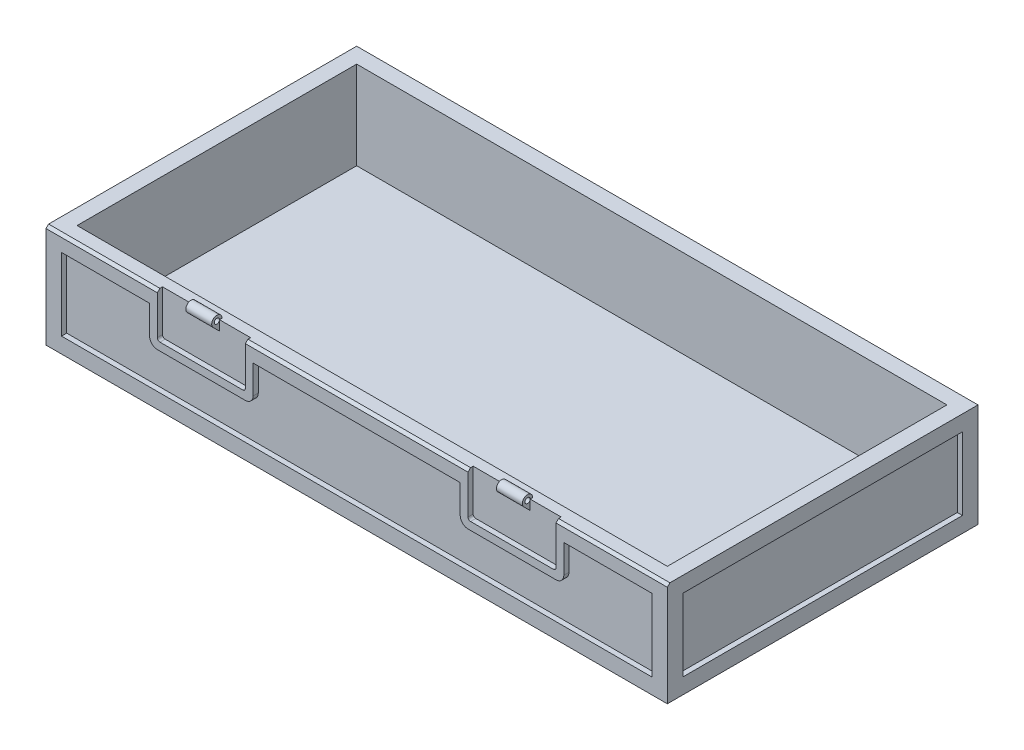
from build123d import *

# Parameters (mm, degrees)
SKETCH1_W                = 120
SKETCH1_H                = 60
BOSS_EXTRUDE1_DEPTH      = 20
SKETCH2_W                = 114
SKETCH2_H                = 54
CUT_EXTRUDE1_DEPTH       = 17
CUT_EXTRUDE2_DEPTH       = 1
CUT_EXTRUDE3_DEPTH       = 1
SKETCH5_W                = 54
SKETCH5_H                = 14
CUT_EXTRUDE4_DEPTH       = 1
SKETCH6_W                = 54
SKETCH6_H                = 14
CUT_EXTRUDE5_DEPTH       = 1
SKETCH7_W                = 114
SKETCH7_H                = 14
CUT_EXTRUDE6_DEPTH       = 1
SKETCH8_W                = 114
SKETCH8_H                = 54
CUT_EXTRUDE7_DEPTH       = 1
BOSS_EXTRUDE2_DEPTH      = 3
BOSS_EXTRUDE2_DEPTH_BACK = 0.5
CUT_EXTRUDE8_DEPTH       = 5
BOSS_EXTRUDE3_DEPTH      = 2
BOSS_EXTRUDE3_DEPTH_BACK = 0.5
CUT_EXTRUDE9_DEPTH       = 5
CUT_EXTRUDE10_DEPTH      = 23
CUT_EXTRUDE11_DEPTH      = 43
CUT_EXTRUDE12_DEPTH      = 43
BOSS_EXTRUDE5_DEPTH      = 1


with BuildPart() as part:
    # Sketch1 → Boss-Extrude1 (new body)
    with BuildSketch(Plane(origin=(0, 0, 0), x_dir=(1, 0, 0), z_dir=(0, 1, 0))):
        with Locations((60, 30)):
            Rectangle(SKETCH1_W, SKETCH1_H)
    extrude(amount=BOSS_EXTRUDE1_DEPTH)

    # Sketch2 → Cut-Extrude1 (cut)
    with BuildSketch(Plane(origin=(0, 20, 0), x_dir=(1, 0, 0), z_dir=(0, 1, 0))):
        with Locations((60, 30)):
            Rectangle(SKETCH2_W, SKETCH2_H)
    extrude(amount=-CUT_EXTRUDE1_DEPTH, mode=Mode.SUBTRACT)

    # Sketch3 → Cut-Extrude2 (cut)
    with BuildSketch(Plane.XY):
        with BuildLine():
            Line((38.5, 20), (21.5, 20))
            Line((21.5, 20), (21.5, 12))
            ThreePointArc((21.5, 12), (21.646446609, 11.646446609), (22, 11.5))
            Line((22, 11.5), (38, 11.5))
            ThreePointArc((38, 11.5), (38.353553391, 11.646446609), (38.5, 12))
            Line((38.5, 12), (38.5, 20))
        make_face()
        with BuildLine():
            Line((98.5, 12), (98.5, 20))
            Line((98.5, 20), (81.5, 20))
            Line((81.5, 20), (81.5, 12))
            ThreePointArc((81.5, 12), (81.646446609, 11.646446609), (82, 11.5))
            Line((82, 11.5), (98, 11.5))
            ThreePointArc((98, 11.5), (98.353553391, 11.646446609), (98.5, 12))
        make_face()
    extrude(amount=-CUT_EXTRUDE2_DEPTH, mode=Mode.SUBTRACT)

    # Sketch4 → Cut-Extrude3 (cut)
    with BuildSketch(Plane.XY):
        with BuildLine():
            Line((20, 17), (3, 17))
            Line((3, 17), (3, 3))
            Line((3, 3), (117, 3))
            Line((117, 3), (117, 17))
            Line((117, 17), (100, 17))
            Line((100, 17), (100, 11.5))
            ThreePointArc((100, 11.5), (99.560660172, 10.439339828), (98.5, 10))
            Line((98.5, 10), (81.5, 10))
            ThreePointArc((81.5, 10), (80.439339828, 10.439339828), (80, 11.5))
            Line((80, 11.5), (80, 17))
            Line((80, 17), (60, 17))
            Line((60, 17), (40, 17))
            Line((40, 17), (40, 11.5))
            ThreePointArc((40, 11.5), (39.560660172, 10.439339828), (38.5, 10))
            Line((38.5, 10), (21.5, 10))
            ThreePointArc((21.5, 10), (20.439339828, 10.439339828), (20, 11.5))
            Line((20, 11.5), (20, 17))
        make_face()
    extrude(amount=-CUT_EXTRUDE3_DEPTH, mode=Mode.SUBTRACT)

    # Sketch5 → Cut-Extrude4 (cut)
    with BuildSketch(Plane.ZY):
        with Locations((-30, 10)):
            Rectangle(SKETCH5_W, SKETCH5_H)
    extrude(amount=-CUT_EXTRUDE4_DEPTH, mode=Mode.SUBTRACT)

    # Sketch6 → Cut-Extrude5 (cut)
    with BuildSketch(Plane(origin=(120, 0, 0), x_dir=(0, 0, -1), z_dir=(1, 0, 0))):
        with Locations((30, 10)):
            Rectangle(SKETCH6_W, SKETCH6_H)
    extrude(amount=-CUT_EXTRUDE5_DEPTH, mode=Mode.SUBTRACT)

    # Sketch7 → Cut-Extrude6 (cut)
    with BuildSketch(Plane(origin=(0, 0, -60), x_dir=(-1, 0, 0), z_dir=(0, 0, -1))):
        with Locations((-60, 10)):
            Rectangle(SKETCH7_W, SKETCH7_H)
    extrude(amount=-CUT_EXTRUDE6_DEPTH, mode=Mode.SUBTRACT)

    # Sketch8 → Cut-Extrude7 (cut)
    with BuildSketch(Plane.XZ):
        with Locations((60, -30)):
            Rectangle(SKETCH8_W, SKETCH8_H)
    extrude(amount=-CUT_EXTRUDE7_DEPTH, mode=Mode.SUBTRACT)

    # Sketch9 → Boss-Extrude2 (add, two sides)
    with BuildSketch(Plane.XY.offset(-1)) as boss_extrude2_sk:
        Polygon((32.5, 20), (30, 20), (27.5, 20), (27.5, 18), (32.5, 18), align=None)
        Polygon((27.5, 20), (30, 20), (32.5, 20), (32.5, 21), (27.5, 21), align=None)
    extrude(amount=BOSS_EXTRUDE2_DEPTH)
    extrude(boss_extrude2_sk.sketch, amount=-BOSS_EXTRUDE2_DEPTH_BACK)

    # Sketch11 → Cut-Extrude8 (cut)
    with BuildSketch(Plane(origin=(32.5, 0, 0), x_dir=(0, 0, -1), z_dir=(1, 0, 0))):
        with BuildLine():
            Line((1, 18.085786438), (-0.207106781, 19.292893219))
            ThreePointArc((-0.207106781, 19.292893219), (-0.423879533, 20.382683432), (0.5, 21))
            Line((0.5, 21), (-2, 21))
            Line((-2, 21), (-2, 18))
            Line((-2, 18), (1, 18))
            Line((1, 18), (1, 18.085786438))
        make_face()
        with BuildLine():
            ThreePointArc((0.5, 21), (1.207106781, 20.707106781), (1.5, 20))
            Line((1.5, 20), (1.5, 21))
            Line((1.5, 21), (0.5, 21))
        make_face()
        with BuildLine():
            ThreePointArc((0.146446609, 19.646446609), (0.691341716, 19.538060234), (1, 20))
            Line((1, 20), (0.5, 20))
            Line((0.5, 20), (0.146446609, 19.646446609))
        make_face()
        with BuildLine():
            Line((0.5, 20), (1, 20))
            ThreePointArc((1, 20), (0.308658284, 20.461939766), (0.146446609, 19.646446609))
            Line((0.146446609, 19.646446609), (0.5, 20))
        make_face()
    extrude(amount=-CUT_EXTRUDE8_DEPTH, mode=Mode.SUBTRACT)

    # Sketch12 → Boss-Extrude3 (add, two sides)
    with BuildSketch(Plane.XY.offset(-1)) as boss_extrude3_sk:
        Polygon((87.5, 21), (87.5, 20), (87.5, 18), (92.5, 18), (92.5, 21), align=None)
    extrude(amount=BOSS_EXTRUDE3_DEPTH)
    extrude(boss_extrude3_sk.sketch, amount=-BOSS_EXTRUDE3_DEPTH_BACK)

    # Sketch13 → Cut-Extrude9 (cut)
    with BuildSketch(Plane(origin=(92.5, 0, 0), x_dir=(0, 0, -1), z_dir=(1, 0, 0))):
        with BuildLine():
            Line((1, 18.085786438), (-0.207106781, 19.292893219))
            ThreePointArc((-0.207106781, 19.292893219), (-0.423879533, 20.382683432), (0.5, 21))
            Line((0.5, 21), (-1, 21))
            Line((-1, 21), (-1, 18))
            Line((-1, 18), (1, 18))
            Line((1, 18), (1, 18.085786438))
        make_face()
        with BuildLine():
            ThreePointArc((0.146446609, 19.646446609), (0.691341716, 19.538060234), (1, 20))
            Line((1, 20), (0.5, 20))
            Line((0.5, 20), (0.146446609, 19.646446609))
        make_face()
        with BuildLine():
            Line((0.5, 20), (1, 20))
            ThreePointArc((1, 20), (0.308658284, 20.461939766), (0.146446609, 19.646446609))
            Line((0.146446609, 19.646446609), (0.5, 20))
        make_face()
        with BuildLine():
            ThreePointArc((0.5, 21), (1.207106781, 20.707106781), (1.5, 20))
            Line((1.5, 20), (1.5, 21))
            Line((1.5, 21), (0.5, 21))
        make_face()
    extrude(amount=-CUT_EXTRUDE9_DEPTH, mode=Mode.SUBTRACT)

    # Sketch14 → Cut-Extrude10 (cut)
    with BuildSketch(Plane.ZY):
        Polygon((0, 19.5), (0, 20), (-0.5, 20), align=None)
    extrude(amount=-CUT_EXTRUDE10_DEPTH, mode=Mode.SUBTRACT)

    # Sketch15 → Cut-Extrude11 (cut)
    with BuildSketch(Plane.ZY.offset(-38.5)):
        Polygon((0, 20), (-0.5, 20), (0, 19.5), align=None)
    extrude(amount=-CUT_EXTRUDE11_DEPTH, mode=Mode.SUBTRACT)

    # Sketch16 → Cut-Extrude12 (cut)
    with BuildSketch(Plane.ZY.offset(-98.5)):
        Polygon((0, 20), (-0.5, 20), (0, 19.5), align=None)
    extrude(amount=-CUT_EXTRUDE12_DEPTH, mode=Mode.SUBTRACT)

    # Sketch18 → Boss-Extrude5 (add)
    with BuildSketch(Plane(origin=(0, 0, 0), x_dir=(-1, 0, 0), z_dir=(0, -1, 0))):
        Polygon((-46.5, 36.75), (-48, 36), (-48, 24), (-60, 24), (-60, 22.5), (-46.5, 22.5), align=None)
        Polygon((-60, 24), (-72, 24), (-73.5, 23.25), (-73.5, 22.5), (-60, 22.5), align=None)
        Polygon((-72, 36), (-48, 36), (-46.5, 36.75), (-46.5, 37.5), (-73.5, 37.5), (-73.5, 23.25), (-72, 24), align=None)
    extrude(amount=-BOSS_EXTRUDE5_DEPTH)


solid = part.part
